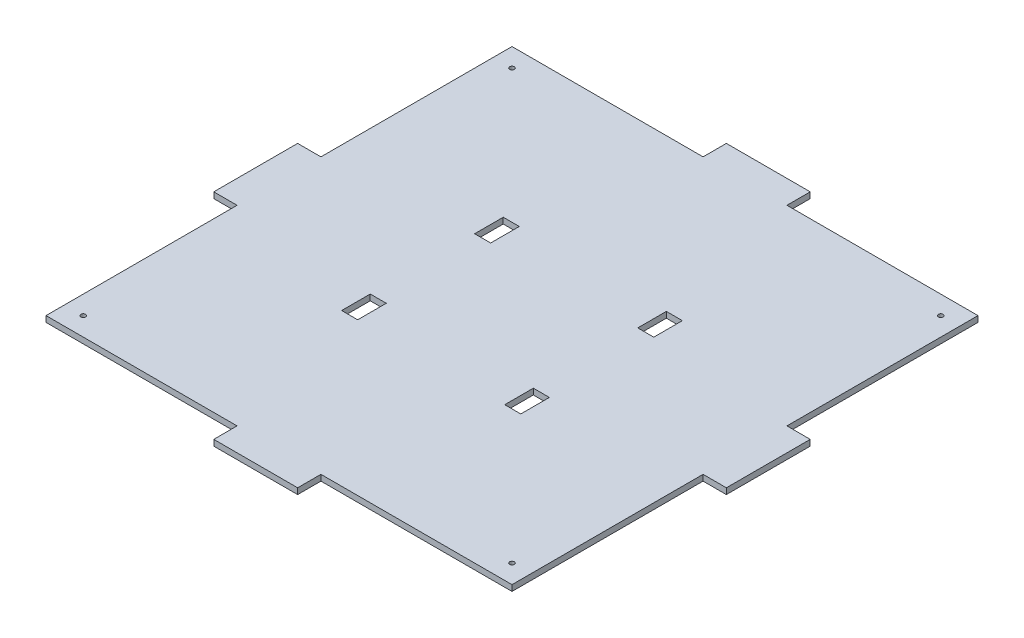
from build123d import *

# Parameters (mm, degrees)
SKETCH2_W           = 250
SKETCH2_H           = 250
BOSS_EXTRUDE1_DEPTH = 3.175
SKETCH3_W           = 8.6
SKETCH3_H           = 15.35
CUT_EXTRUDE1_DEPTH  = 10
SKETCH10_W          = 45
SKETCH10_H          = 3.175
BOSS_EXTRUDE2_DEPTH = 12.5
SKETCH11_W          = 45
SKETCH11_H          = 3.175
BOSS_EXTRUDE3_DEPTH = 12.5
SKETCH13_W          = 45
SKETCH13_H          = 3.175
BOSS_EXTRUDE4_DEPTH = 12.5
SKETCH14_W          = 45
SKETCH14_H          = 3.175
BOSS_EXTRUDE5_DEPTH = 12.5
M3_TAPPED_HOLE1_D   = 2.5
SKETCH21_R          = 1.25
CUT_EXTRUDE2_DEPTH  = 10


with BuildPart() as part:
    # Sketch2 → Boss-Extrude1 (new body)
    with BuildSketch(Plane(origin=(0, 0, 0), x_dir=(1, 0, 0), z_dir=(0, 1, 0))):
        Rectangle(SKETCH2_W, SKETCH2_H)
    extrude(amount=BOSS_EXTRUDE1_DEPTH)

    # Sketch3 → Cut-Extrude1 (cut)
    with BuildSketch(Plane(origin=(0, 3.175, 0), x_dir=(1, 0, 0), z_dir=(0, 1, 0))):
        with Locations((-43.75, 35.675)):
            Rectangle(SKETCH3_W, SKETCH3_H)
        with Locations((-43.75, -35.675)):
            Rectangle(SKETCH3_W, SKETCH3_H)
        with Locations((43.75, -35.675)):
            Rectangle(SKETCH3_W, SKETCH3_H)
        with Locations((43.75, 35.675)):
            Rectangle(SKETCH3_W, SKETCH3_H)
    extrude(amount=-CUT_EXTRUDE1_DEPTH, mode=Mode.SUBTRACT)

    # Sketch10 → Boss-Extrude2 (add)
    with BuildSketch(Plane(origin=(0, 0, -125), x_dir=(-1, 0, 0), z_dir=(0, 0, -1))):
        with Locations((0, 1.5875)):
            Rectangle(SKETCH10_W, SKETCH10_H)
    extrude(amount=BOSS_EXTRUDE2_DEPTH)

    # Sketch11 → Boss-Extrude3 (add)
    with BuildSketch(Plane.ZY.offset(125)):
        with Locations((0, 1.5875)):
            Rectangle(SKETCH11_W, SKETCH11_H)
    extrude(amount=BOSS_EXTRUDE3_DEPTH)

    # Sketch13 → Boss-Extrude4 (add)
    with BuildSketch(Plane.XY.offset(125)):
        with Locations((0, 1.5875)):
            Rectangle(SKETCH13_W, SKETCH13_H)
    extrude(amount=BOSS_EXTRUDE4_DEPTH)

    # Sketch14 → Boss-Extrude5 (add)
    with BuildSketch(Plane(origin=(125, 0, 0), x_dir=(0, 0, -1), z_dir=(1, 0, 0))):
        with Locations((0, 1.5875)):
            Rectangle(SKETCH14_W, SKETCH14_H)
    extrude(amount=BOSS_EXTRUDE5_DEPTH)

    # M3 Tapped Hole1 (through all)
    with Locations(Plane(origin=(-115, 3.175, -115), x_dir=(0, 0, 1), z_dir=(0, 1, 0))):
        with Locations((0, 0)):
            Hole(M3_TAPPED_HOLE1_D / 2)

    # Sketch21 → Cut-Extrude2 (cut)
    with BuildSketch(Plane(origin=(0, 3.175, 0), x_dir=(1, 0, 0), z_dir=(0, 1, 0))):
        with Locations((115, 115)):
            Circle(SKETCH21_R)
        with Locations((115, -115)):
            Circle(SKETCH21_R)
        with Locations((-115, -115)):
            Circle(SKETCH21_R)
    extrude(amount=-CUT_EXTRUDE2_DEPTH, mode=Mode.SUBTRACT)


solid = part.part
